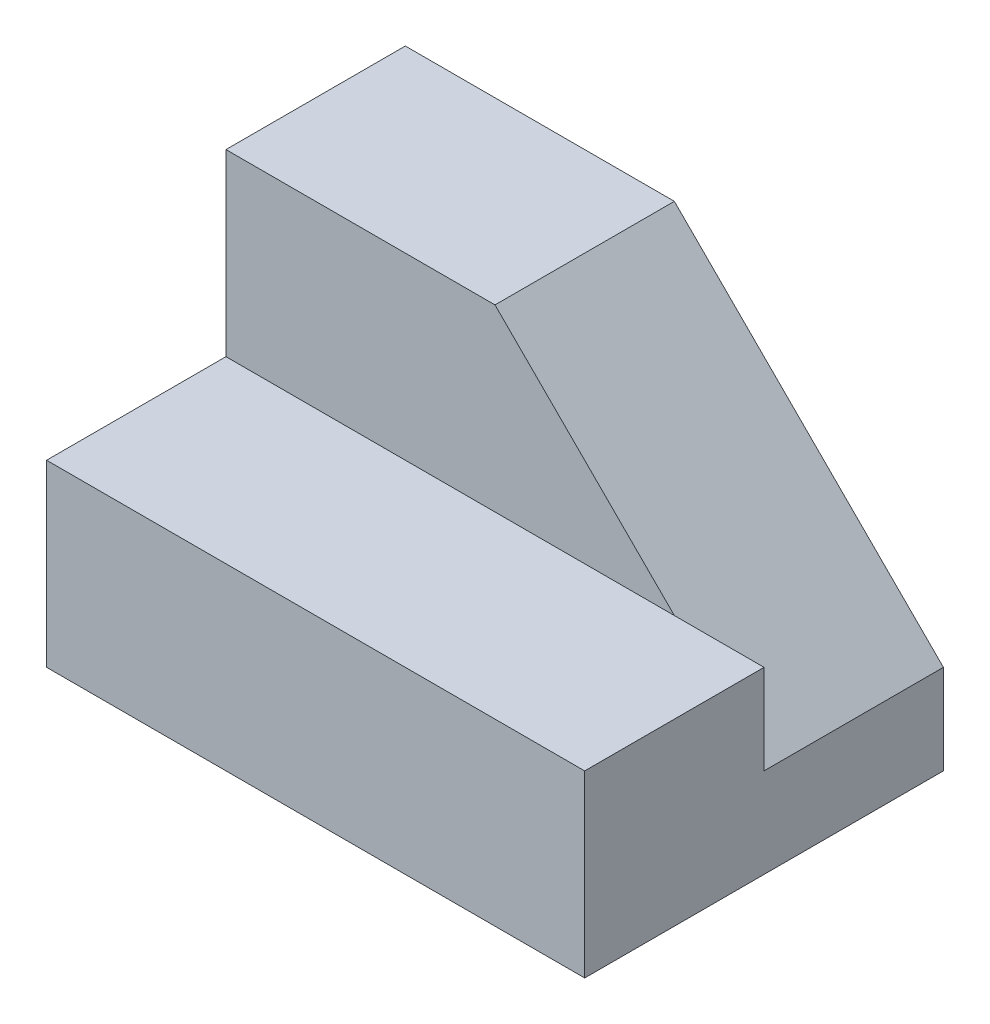
from build123d import *

# Parameters (mm, degrees)
SKETCH_1_W          = 30
SKETCH_1_H          = 20
EXTRUDE_1_DEPTH     = 10
SKETCH_1_3_W        = 30
SKETCH_1_3_H        = 10
EXTRUDE_2_DEPTH     = 20
CUT_EXTRUDE_1_DEPTH = 10
SCALE_1_SCALE       = 0.2


with BuildPart() as part:
    # 草圖1 → 填料-伸長1 (new body)
    with BuildSketch(Plane(origin=(0, 0, 0), x_dir=(1, 0, 0), z_dir=(0, 1, 0))):
        Rectangle(SKETCH_1_W, SKETCH_1_H)
    extrude(amount=EXTRUDE_1_DEPTH)

    # 草圖1<3> → 填料-伸長2 (add)
    with BuildSketch(Plane(origin=(0, 0, 0), x_dir=(1, 0, 0), z_dir=(0, 1, 0))):
        with Locations((0, 5)):
            Rectangle(SKETCH_1_3_W, SKETCH_1_3_H)
    extrude(amount=EXTRUDE_2_DEPTH)

    # 草圖2 → 除料-伸長1 (cut)
    with BuildSketch(Plane(origin=(0, 0, -10), x_dir=(-1, 0, 0), z_dir=(0, 0, -1))):
        Polygon((-15, 5), (0, 20), (-15, 20), align=None)
    extrude(amount=-CUT_EXTRUDE_1_DEPTH, mode=Mode.SUBTRACT)


with BuildPart() as part_1:
    # 縮放比例1: scaled about (-1.428571429, 7.380952381, -1.19047619)
    add(part.part.scale(SCALE_1_SCALE).moved(Location((-1.142857143, 5.904761905, -0.952380952))))


solid = part_1.part
